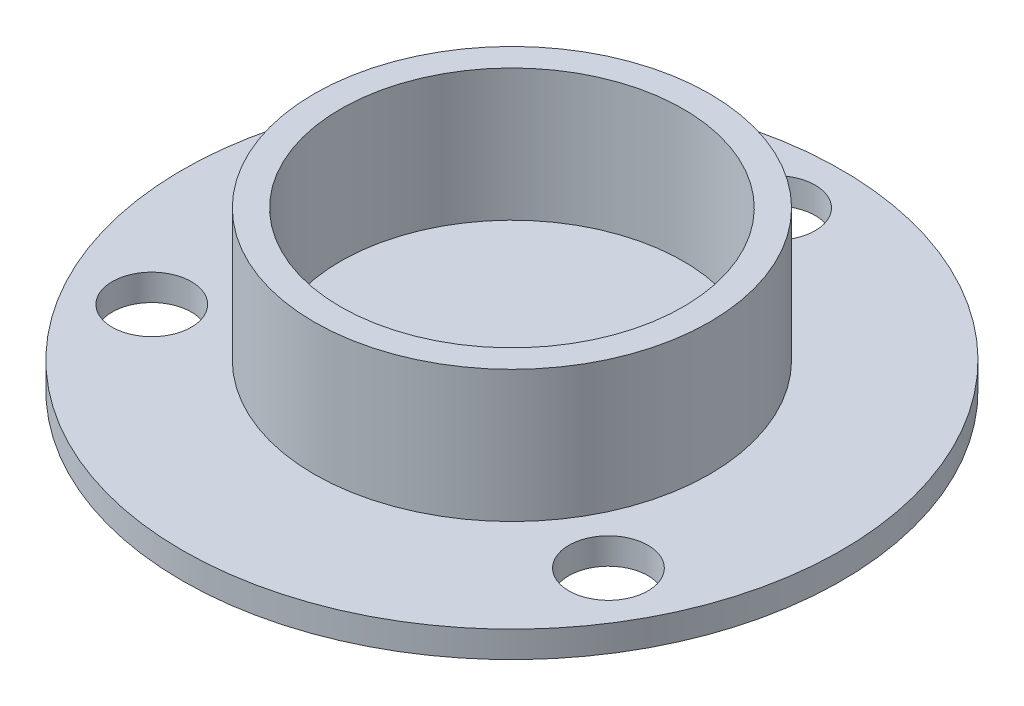
from build123d import *

# Parameters (mm, degrees)
SKETCH2_R           = 12.5
SKETCH2_R_2         = 1.5
BOSS_EXTRUDE1_DEPTH = 1
SKETCH3_R           = 7.5
SKETCH3_R_2         = 6.5
BOSS_EXTRUDE2_DEPTH = 5


with BuildPart() as part:
    # Sketch2 → Boss-Extrude1 (new body)
    with BuildSketch(Plane(origin=(0, 0, 0), x_dir=(1, 0, 0), z_dir=(0, 1, 0))):
        Circle(SKETCH2_R)
        with Locations((0, 10)):
            Circle(SKETCH2_R_2, mode=Mode.SUBTRACT)
        with Locations((8.660254038, -5)):
            Circle(SKETCH2_R_2, mode=Mode.SUBTRACT)
        with Locations((-8.660254038, -5)):
            Circle(SKETCH2_R_2, mode=Mode.SUBTRACT)
    extrude(amount=BOSS_EXTRUDE1_DEPTH)

    # Sketch3 → Boss-Extrude2 (add)
    with BuildSketch(Plane(origin=(0, 1, 0), x_dir=(1, 0, 0), z_dir=(0, 1, 0))):
        Circle(SKETCH3_R)
        Circle(SKETCH3_R_2, mode=Mode.SUBTRACT)
    extrude(amount=BOSS_EXTRUDE2_DEPTH)


solid = part.part
